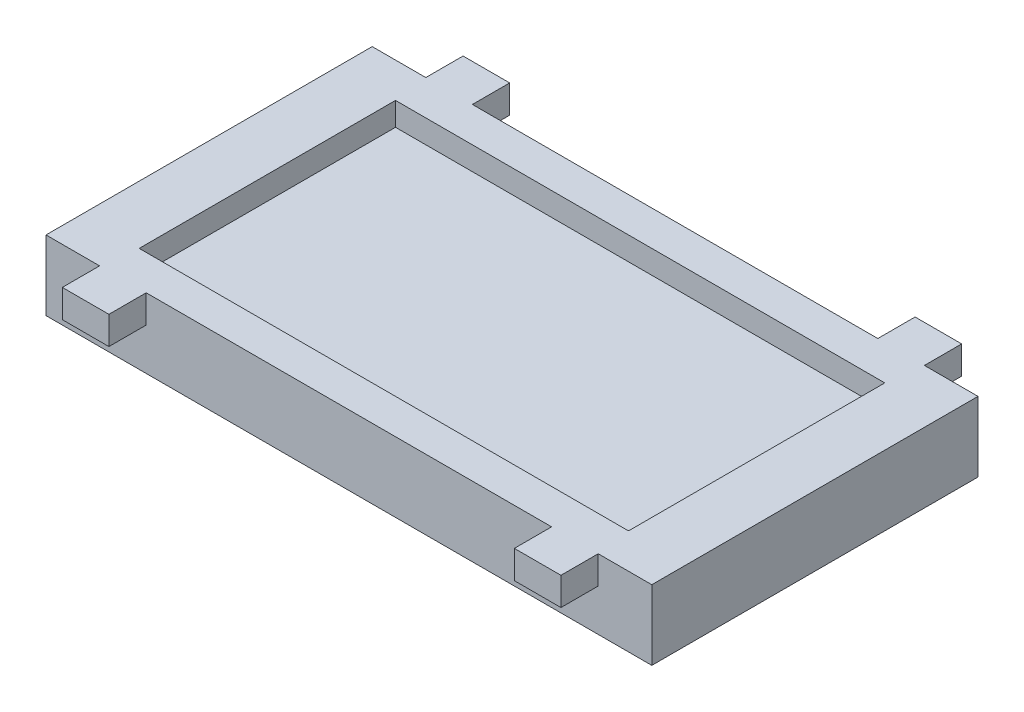
from build123d import *

# Parameters (mm, degrees)
SKETCH1_W           = 1300
SKETCH1_H           = 700
BOSS_EXTRUDE1_DEPTH = 150
SKETCH2_W           = 1050
SKETCH2_H           = 550
CUT_EXTRUDE1_DEPTH  = 50
SKETCH3_W           = 1050
SKETCH3_H           = 550
CUT_EXTRUDE2_DEPTH  = 50
SKETCH14_W          = 100
SKETCH14_H          = 80
BOSS_EXTRUDE3_DEPTH = 60
SKETCH15_W          = 93
SKETCH15_H          = 55
CUT_EXTRUDE7_DEPTH  = 40
SKETCH16_W          = 100
SKETCH16_H          = 80
BOSS_EXTRUDE4_DEPTH = 60


with BuildPart() as part:
    # Sketch1 → Boss-Extrude1 (new body)
    with BuildSketch(Plane(origin=(0, 0, 0), x_dir=(1, 0, 0), z_dir=(0, 1, 0))):
        Rectangle(SKETCH1_W, SKETCH1_H)
    extrude(amount=BOSS_EXTRUDE1_DEPTH)

    # Sketch2 → Cut-Extrude1 (cut)
    with BuildSketch(Plane(origin=(0, 150, 0), x_dir=(1, 0, 0), z_dir=(0, 1, 0))):
        Rectangle(SKETCH2_W, SKETCH2_H)
    extrude(amount=-CUT_EXTRUDE1_DEPTH, mode=Mode.SUBTRACT)

    # Sketch3 → Cut-Extrude2 (cut)
    with BuildSketch(Plane.XZ):
        Rectangle(SKETCH3_W, SKETCH3_H)
    extrude(amount=-CUT_EXTRUDE2_DEPTH, mode=Mode.SUBTRACT)

    # Sketch14 → Boss-Extrude3 (add)
    with BuildSketch(Plane(origin=(0, 150, 0), x_dir=(1, 0, 0), z_dir=(0, 1, 0))):
        with Locations((485, -390)):
            Rectangle(SKETCH14_W, SKETCH14_H)
        with Locations((-485, -390)):
            Rectangle(SKETCH14_W, SKETCH14_H)
    extrude(amount=-BOSS_EXTRUDE3_DEPTH)

    # Sketch15 → Cut-Extrude7 (cut)
    with BuildSketch(Plane.XZ.offset(-90)):
        with Locations((485.587200579, 389.924483471)):
            Rectangle(SKETCH15_W, SKETCH15_H)
    extrude(amount=-CUT_EXTRUDE7_DEPTH, mode=Mode.SUBTRACT)

    # Sketch16 → Boss-Extrude4 (add)
    with BuildSketch(Plane(origin=(0, 150, 0), x_dir=(1, 0, 0), z_dir=(0, 1, 0))):
        with Locations((485, 390)):
            Rectangle(SKETCH16_W, SKETCH16_H)
        with Locations((-485, 390)):
            Rectangle(SKETCH16_W, SKETCH16_H)
    extrude(amount=-BOSS_EXTRUDE4_DEPTH)


solid = part.part
